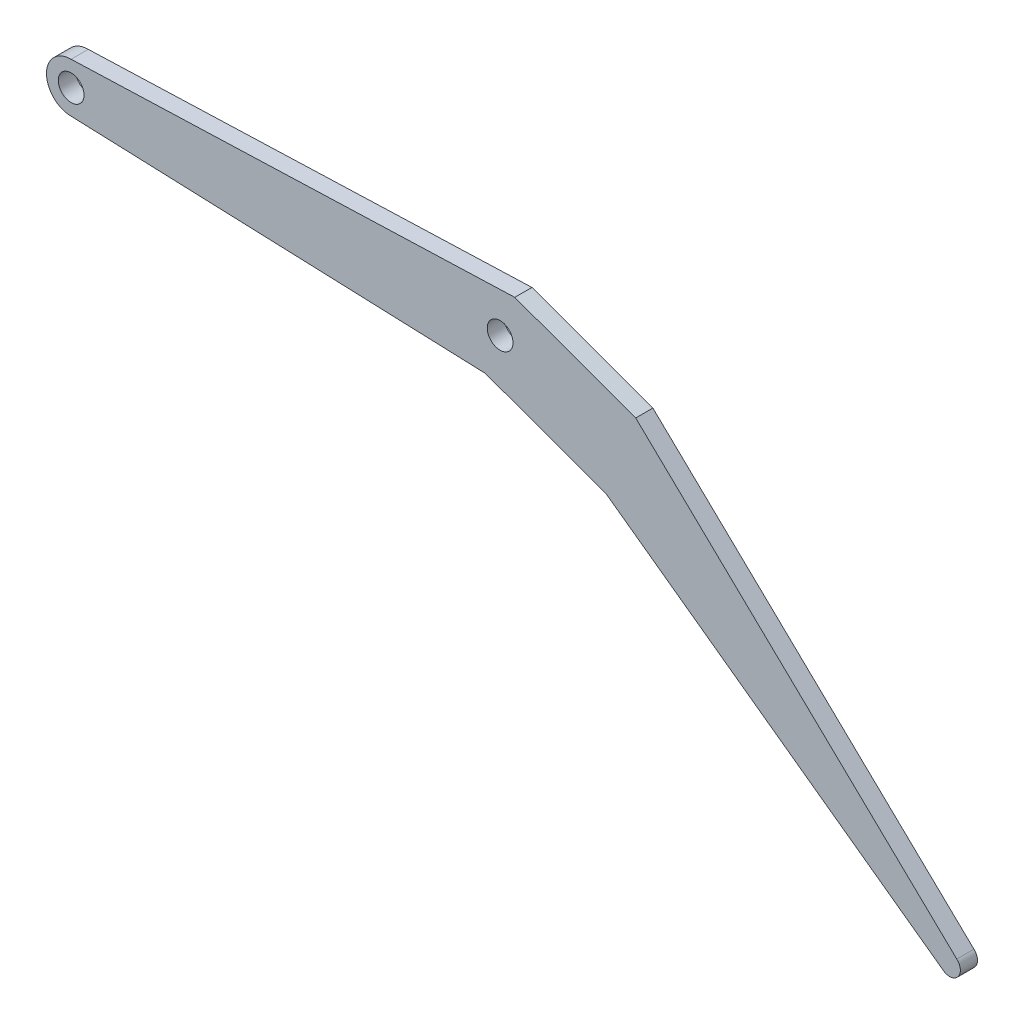
from build123d import *

# Parameters (mm, degrees)
SKETCH1_R      = 3
EXTRUDE1_DEPTH = 4


with BuildPart() as part:
    # Sketch1 → Extrude1 (new body)
    with BuildSketch(Plane.XY):
        with BuildLine():
            Line((96.579798567, -9.396926208), (124.77057719, -19.657530508))
            Line((124.77057719, -19.657530508), (203.128908943, -76.403070631))
            ThreePointArc((203.128908943, -76.403070631), (206.658928298, -76.205679261), (206.461536928, -72.675659906))
            Line((206.461536928, -72.675659906), (131.610980057, -0.863678092))
            Line((131.610980057, -0.863678092), (103.420201433, 9.396926208))
            Line((103.420201433, 9.396926208), (-0.005150596, 5.749997693))
            ThreePointArc((-0.005150596, 5.749997693), (-5.74995391, -0.023022325), (0.040893831, -5.74985458))
            Line((0.040893831, -5.74985458), (96.579798567, -9.396926208))
        make_face()
        Circle(SKETCH1_R, mode=Mode.SUBTRACT)
        with Locations((100, 0)):
            Circle(SKETCH1_R, mode=Mode.SUBTRACT)
    extrude(amount=EXTRUDE1_DEPTH)


solid = part.part
